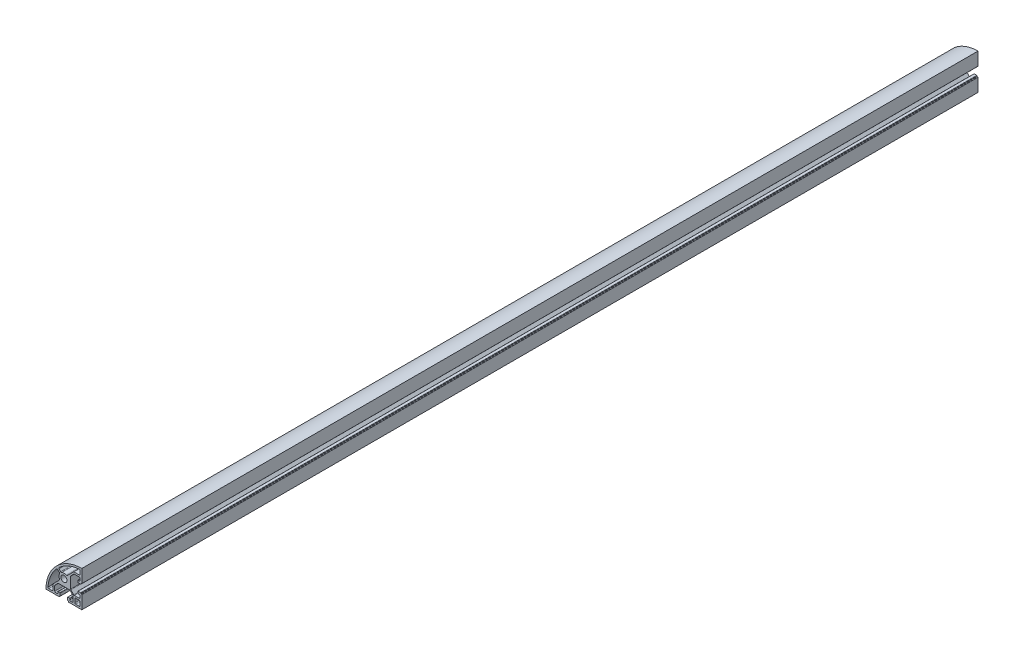
from build123d import *

# Parameters (mm, degrees)
SKETCH_1_R      = 3.4
EXTRUDE_1_DEPTH = 1000


with BuildPart() as part:
    # Эскиз1 → Бобышка-Вытянуть1 (new body)
    with BuildSketch(Plane.XY):
        with BuildLine():
            Line((5.4, -20), (10.25, -20))
            Line((10.25, -20), (20, -20))
            Line((20, -20), (20, -10.25))
            Line((20, -10.25), (20, -5.4))
            ThreePointArc((20, -5.4), (19.912132034, -5.187867966), (19.7, -5.1))
            Line((19.7, -5.1), (19.3, -5.1))
            ThreePointArc((19.3, -5.1), (19.087867966, -5.012132034), (19, -4.8))
            Line((19, -4.8), (19, -4.4))
            ThreePointArc((19, -4.4), (18.912132034, -4.187867966), (18.7, -4.1))
            Line((18.7, -4.1), (15.8, -4.1))
            ThreePointArc((15.8, -4.1), (15.587867966, -4.187867966), (15.5, -4.4))
            Line((15.5, -4.4), (15.5, -6.3))
            ThreePointArc((15.5, -6.3), (15.587867966, -6.512132034), (15.8, -6.6))
            Line((15.8, -6.6), (17, -6.6))
            ThreePointArc((17, -6.6), (17.707106781, -6.892893219), (18, -7.6))
            Line((18, -7.6), (18, -9.25))
            ThreePointArc((18, -9.25), (17.707106781, -9.957106781), (17, -10.25))
            Line((17, -10.25), (11.664213562, -10.25))
            ThreePointArc((11.664213562, -10.25), (11.28153013, -10.173879533), (10.957106781, -9.957106781))
            Line((10.957106781, -9.957106781), (7.792893219, -6.792893219))
            ThreePointArc((7.792893219, -6.792893219), (7.576120467, -6.46846987), (7.5, -6.085786438))
            Line((7.5, -6.085786438), (7.5, 6.085786438))
            ThreePointArc((7.5, 6.085786438), (7.576120467, 6.46846987), (7.792893219, 6.792893219))
            Line((7.792893219, 6.792893219), (10.957106781, 9.957106781))
            ThreePointArc((10.957106781, 9.957106781), (11.28153013, 10.173879533), (11.664213562, 10.25))
            Line((11.664213562, 10.25), (17, 10.25))
            ThreePointArc((17, 10.25), (17.707106781, 9.957106781), (18, 9.25))
            Line((18, 9.25), (18, 7.6))
            ThreePointArc((18, 7.6), (17.707106781, 6.892893219), (17, 6.6))
            Line((17, 6.6), (15.8, 6.6))
            ThreePointArc((15.8, 6.6), (15.587867966, 6.512132034), (15.5, 6.3))
            Line((15.5, 6.3), (15.5, 4.4))
            ThreePointArc((15.5, 4.4), (15.587867966, 4.187867966), (15.8, 4.1))
            Line((15.8, 4.1), (18.7, 4.1))
            ThreePointArc((18.7, 4.1), (18.912132034, 4.187867966), (19, 4.4))
            Line((19, 4.4), (19, 4.8))
            ThreePointArc((19, 4.8), (19.087867966, 5.012132034), (19.3, 5.1))
            Line((19.3, 5.1), (19.7, 5.1))
            ThreePointArc((19.7, 5.1), (19.912132034, 5.187867966), (20, 5.4))
            Line((20, 5.4), (20, 10.25))
            Line((20, 10.25), (20, 20))
            ThreePointArc((20, 20), (-8.284271247, 8.284271247), (-20, -20))
            Line((-20, -20), (-10.25, -20))
            Line((-10.25, -20), (-5.4, -20))
            ThreePointArc((-5.4, -20), (-5.187867966, -19.912132034), (-5.1, -19.7))
            Line((-5.1, -19.7), (-5.1, -19.3))
            ThreePointArc((-5.1, -19.3), (-5.012132034, -19.087867966), (-4.8, -19))
            Line((-4.8, -19), (-4.4, -19))
            ThreePointArc((-4.4, -19), (-4.187867966, -18.912132034), (-4.1, -18.7))
            Line((-4.1, -18.7), (-4.1, -15.8))
            ThreePointArc((-4.1, -15.8), (-4.187867966, -15.587867966), (-4.4, -15.5))
            Line((-4.4, -15.5), (-6.3, -15.5))
            ThreePointArc((-6.3, -15.5), (-6.512132034, -15.587867966), (-6.6, -15.8))
            Line((-6.6, -15.8), (-6.6, -17))
            ThreePointArc((-6.6, -17), (-6.892893219, -17.707106781), (-7.6, -18))
            Line((-7.6, -18), (-9.25, -18))
            ThreePointArc((-9.25, -18), (-9.957106781, -17.707106781), (-10.25, -17))
            Line((-10.25, -17), (-10.25, -11.664213562))
            ThreePointArc((-10.25, -11.664213562), (-10.173879533, -11.28153013), (-9.957106781, -10.957106781))
            Line((-9.957106781, -10.957106781), (-6.792893219, -7.792893219))
            ThreePointArc((-6.792893219, -7.792893219), (-6.46846987, -7.576120467), (-6.085786438, -7.5))
            Line((-6.085786438, -7.5), (6.085786438, -7.5))
            ThreePointArc((6.085786438, -7.5), (6.46846987, -7.576120467), (6.792893219, -7.792893219))
            Line((6.792893219, -7.792893219), (9.957106781, -10.957106781))
            ThreePointArc((9.957106781, -10.957106781), (10.173879533, -11.28153013), (10.25, -11.664213562))
            Line((10.25, -11.664213562), (10.25, -17))
            ThreePointArc((10.25, -17), (9.957106781, -17.707106781), (9.25, -18))
            Line((9.25, -18), (7.6, -18))
            ThreePointArc((7.6, -18), (6.892893219, -17.707106781), (6.6, -17))
            Line((6.6, -17), (6.6, -15.8))
            ThreePointArc((6.6, -15.8), (6.512132034, -15.587867966), (6.3, -15.5))
            Line((6.3, -15.5), (4.4, -15.5))
            ThreePointArc((4.4, -15.5), (4.187867966, -15.587867966), (4.1, -15.8))
            Line((4.1, -15.8), (4.1, -18.7))
            ThreePointArc((4.1, -18.7), (4.187867966, -18.912132034), (4.4, -19))
            Line((4.4, -19), (4.8, -19))
            ThreePointArc((4.8, -19), (5.012132034, -19.087867966), (5.1, -19.3))
            Line((5.1, -19.3), (5.1, -19.7))
            ThreePointArc((5.1, -19.7), (5.187867966, -19.912132034), (5.4, -20))
        make_face()
        with BuildLine():
            Line((-13.247331922, -18), (-16.878177829, -18))
            ThreePointArc((-16.878177829, -18), (-17.613392451, -17.677834389), (-17.874885338, -16.918918919))
            ThreePointArc((-17.874885338, -16.918918919), (-14.907238495, -4.983852003), (-8.283209505, 5.378338403))
            ThreePointArc((-8.283209505, 5.378338403), (-7.565951428, 5.710121829), (-6.831807736, 5.417594174))
            Line((-6.831807736, 5.417594174), (-5.080320702, 3.66610714))
            ThreePointArc((-5.080320702, 3.66610714), (-4.799630461, 3.114747086), (-4.897054025, 2.503769534))
            ThreePointArc((-4.897054025, 2.503769534), (-5.499751223, -0.052311407), (-4.848542652, -2.596465704))
            ThreePointArc((-4.848542652, -2.596465704), (-4.740862187, -3.21489496), (-5.02298908, -3.775657158))
            Line((-5.02298908, -3.775657158), (-12.247331922, -11))
            Line((-12.247331922, -11), (-12.247331922, -17))
            ThreePointArc((-12.247331922, -17), (-12.540225141, -17.707106781), (-13.247331922, -18))
        make_face(mode=Mode.SUBTRACT)
        with BuildLine():
            ThreePointArc((12.2, -13.2), (12.492893219, -12.492893219), (13.2, -12.2))
            Line((13.2, -12.2), (17, -12.2))
            ThreePointArc((17, -12.2), (17.707106781, -12.492893219), (18, -13.2))
            Line((18, -13.2), (18, -17))
            ThreePointArc((18, -17), (17.707106781, -17.707106781), (17, -18))
            Line((17, -18), (13.2, -18))
            ThreePointArc((13.2, -18), (12.492893219, -17.707106781), (12.2, -17))
            Line((12.2, -17), (12.2, -13.2))
        make_face(mode=Mode.SUBTRACT)
        Circle(SKETCH_1_R, mode=Mode.SUBTRACT)
        with BuildLine():
            Line((-3.66610714, 5.080320702), (-5.417594174, 6.831807736))
            ThreePointArc((-5.417594174, 6.831807736), (-5.710121829, 7.565951428), (-5.378338403, 8.283209505))
            ThreePointArc((-5.378338403, 8.283209505), (4.983852003, 14.907238495), (16.918918919, 17.874885338))
            ThreePointArc((16.918918919, 17.874885338), (17.677834389, 17.613392451), (18, 16.878177829))
            Line((18, 16.878177829), (18, 13.247331922))
            ThreePointArc((18, 13.247331922), (17.707106781, 12.540225141), (17, 12.247331922))
            Line((17, 12.247331922), (11, 12.247331922))
            Line((11, 12.247331922), (3.775657158, 5.02298908))
            ThreePointArc((3.775657158, 5.02298908), (3.21489496, 4.740862187), (2.596465704, 4.848542652))
            ThreePointArc((2.596465704, 4.848542652), (0.052311407, 5.499751223), (-2.503769534, 4.897054025))
            ThreePointArc((-2.503769534, 4.897054025), (-3.114747086, 4.799630461), (-3.66610714, 5.080320702))
        make_face(mode=Mode.SUBTRACT)
    extrude(amount=EXTRUDE_1_DEPTH)


solid = part.part
